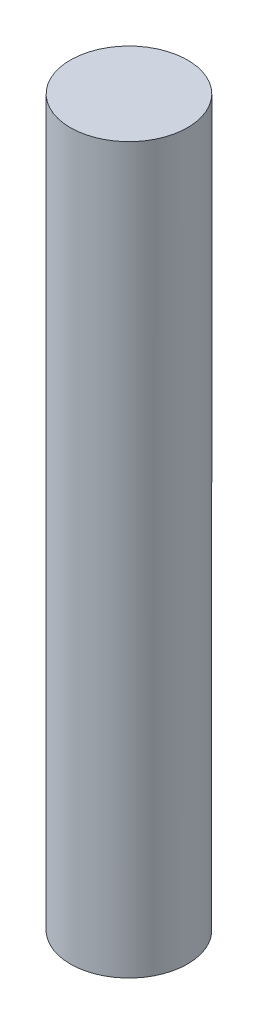
from build123d import *

# Parameters (mm, degrees)
SKETCH1_R               = 3
BOSS_EXTRUDE1_DEPTH     = 80
SKETCH2_R               = 6.35
BOSS_EXTRUDE2_DEPTH     = 600
CUT_EXTRUDE1_DEPTH      = 7
CUT_EXTRUDE1_DEPTH_BACK = 7
SKETCH3_W               = 12.7
SKETCH3_H               = 521.5


with BuildPart() as part:
    # Sketch1 → Boss-Extrude1 (new body)
    with BuildSketch(Plane(origin=(0, 0, 0), x_dir=(1, 0, 0), z_dir=(0, 1, 0))):
        Circle(SKETCH1_R)
    extrude(amount=BOSS_EXTRUDE1_DEPTH)

    # Sketch2 → Boss-Extrude2 (add)
    with BuildSketch(Plane(origin=(0, 80, 0), x_dir=(1, 0, 0), z_dir=(0, 1, 0))):
        Circle(SKETCH2_R)
    extrude(amount=-BOSS_EXTRUDE2_DEPTH)

    # Sketch3 → Cut-Extrude1 (cut, two sides: drawn at the far end of the back side and taken through both)
    with BuildSketch(Plane(origin=(0, 0, 0), x_dir=(0, 0, -1), z_dir=(1, 0, 0)).offset(-CUT_EXTRUDE1_DEPTH_BACK)):
        with Locations((0, -259.25)):
            Rectangle(SKETCH3_W, SKETCH3_H)
    extrude(amount=CUT_EXTRUDE1_DEPTH + CUT_EXTRUDE1_DEPTH_BACK, mode=Mode.SUBTRACT)


solid = part.part
